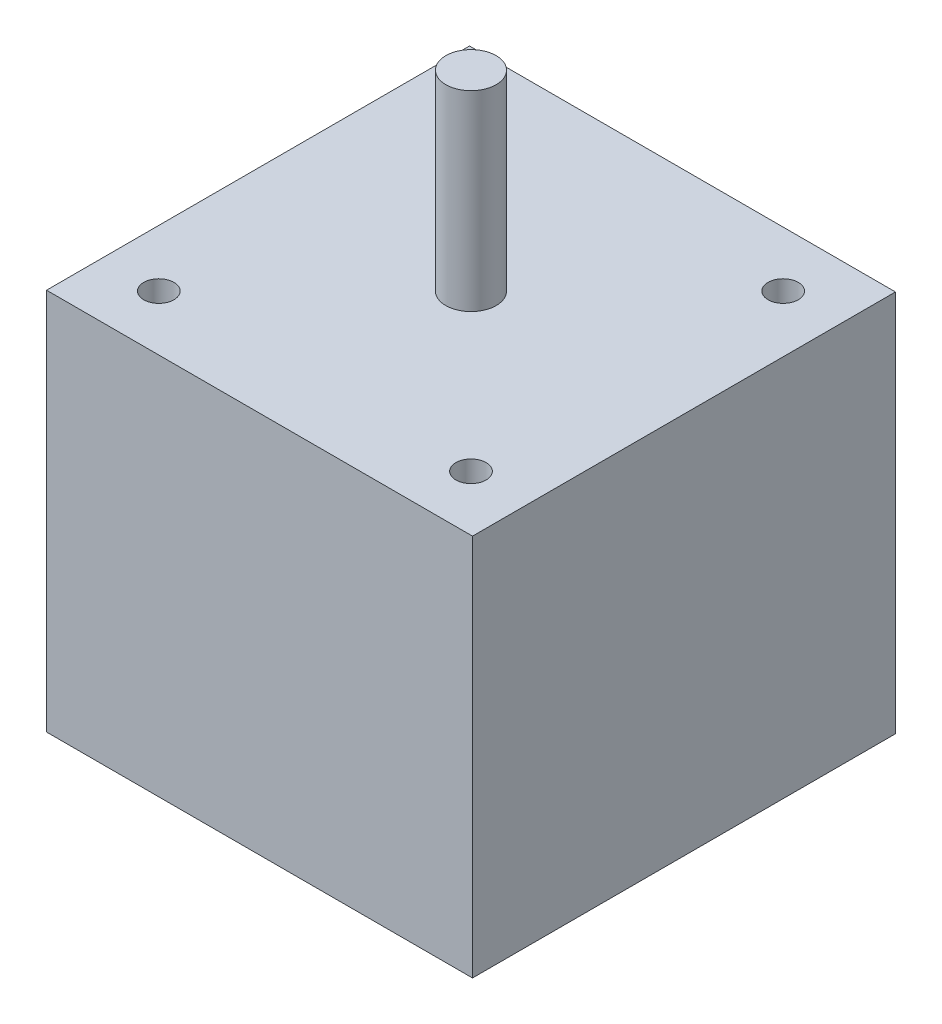
from build123d import *

# Parameters (mm, degrees)
SKETCH1_W           = 42.3
SKETCH1_H           = 42
BOSS_EXTRUDE1_DEPTH = 38
SKETCH2_R           = 2.5
BOSS_EXTRUDE2_DEPTH = 19
SKETCH3_R           = 1.5
CUT_EXTRUDE1_DEPTH  = 4.5


with BuildPart() as part:
    # Sketch1 → Boss-Extrude1 (new body)
    with BuildSketch(Plane(origin=(0, 0, 0), x_dir=(1, 0, 0), z_dir=(0, 1, 0))):
        Rectangle(SKETCH1_W, SKETCH1_H)
    extrude(amount=BOSS_EXTRUDE1_DEPTH)

    # Sketch2 → Boss-Extrude2 (add)
    with BuildSketch(Plane(origin=(0, 38, 0), x_dir=(1, 0, 0), z_dir=(0, 1, 0))):
        Circle(SKETCH2_R)
    extrude(amount=BOSS_EXTRUDE2_DEPTH)

    # Sketch3 → Cut-Extrude1 (cut)
    with BuildSketch(Plane(origin=(0, 38, 0), x_dir=(1, 0, 0), z_dir=(0, 1, 0))):
        with Locations((-15.5, 15.5)):
            Circle(SKETCH3_R)
        with Locations((15.5, 15.5)):
            Circle(SKETCH3_R)
        with Locations((15.5, -15.5)):
            Circle(SKETCH3_R)
        with Locations((-15.5, -15.5)):
            Circle(SKETCH3_R)
    extrude(amount=-CUT_EXTRUDE1_DEPTH, mode=Mode.SUBTRACT)


solid = part.part
